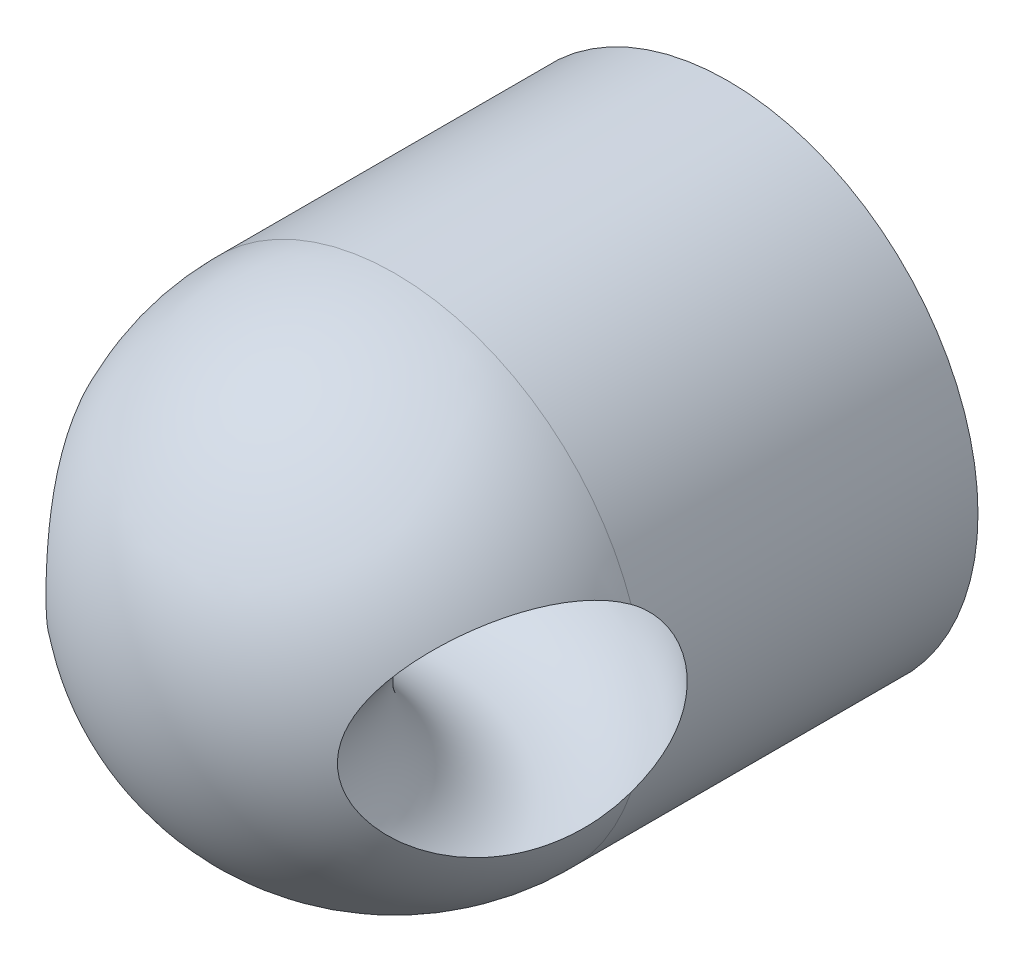
from build123d import *

# Parameters (mm, degrees)
SKETCH1_R   = 6
SKETCH1_R_2 = 1.25
MAIN_DEPTH  = 8
SKETCH4_R   = 2.5


with BuildPart() as part:
    # Sketch1 → Main (new body)
    with BuildSketch(Plane.XY):
        Circle(SKETCH1_R)
        Circle(SKETCH1_R_2, mode=Mode.SUBTRACT)
    extrude(amount=MAIN_DEPTH)

    # Sketch3 → TopMain (revolve)
    with BuildSketch(Plane(origin=(0, 0, 0), x_dir=(0, 0, -1), z_dir=(1, 0, 0))):
        with BuildLine():
            Line((-8, 0), (-14, 0))
            ThreePointArc((-14, 0), (-12.242640687, -4.242640687), (-8, -6))
            Line((-8, -6), (-8, 0))
        make_face()
    revolve(axis=Axis((0, 0, 10.5), (0, 0, -1)))

    # Sketch4 → HookHole (revolve, cut)
    with BuildSketch(Plane(origin=(0, 0, 0), x_dir=(0, 0, -1), z_dir=(1, 0, 0))):
        with Locations((-7, 0)):
            Circle(SKETCH4_R)
    revolve(axis=Axis((0, 6.6, 13), (0, -1, 0)), mode=Mode.SUBTRACT)


solid = part.part
